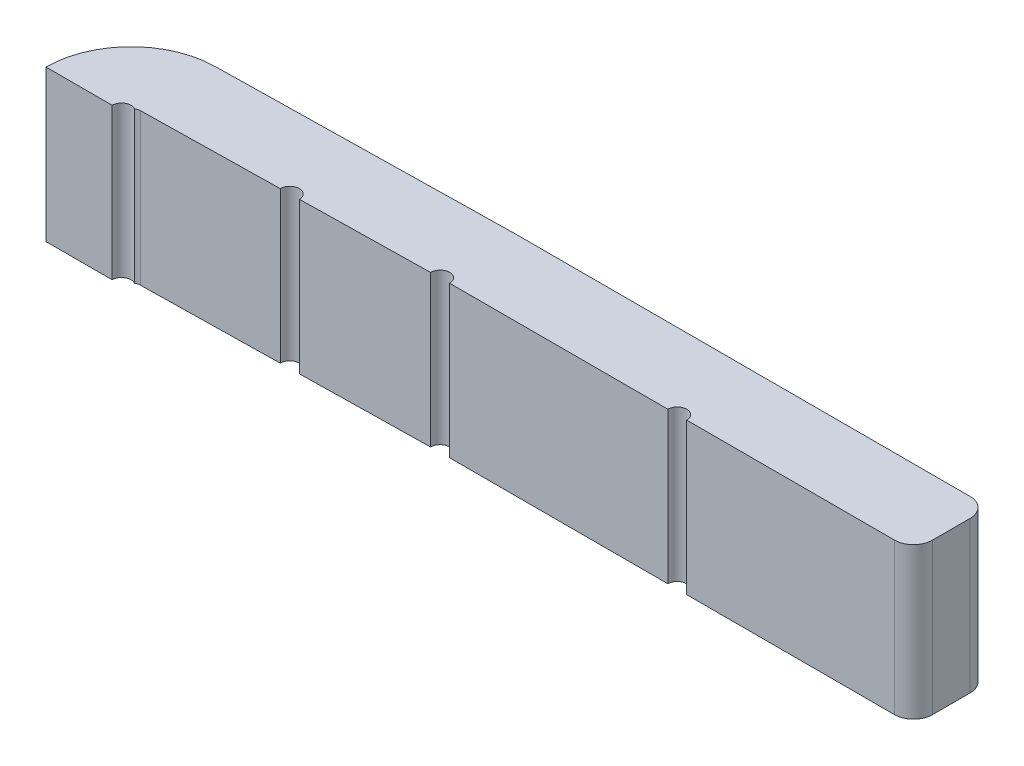
from build123d import *

# Parameters (mm, degrees)
BOSS_EXTRUDE1_DEPTH = 0.8
SKETCH2_R           = 0.05
CUT_EXTRUDE1_DEPTH  = 10
FILLET2_R           = 0.1


with BuildPart() as part:
    # Sketch1 → Boss-Extrude1 (new body)
    with BuildSketch(Plane(origin=(0, 0, 0), x_dir=(1, 0, 0), z_dir=(0, 1, 0))):
        with BuildLine():
            Line((-0.2, 0), (0.2, 0))
            ThreePointArc((0.2, 0), (0.214337478, 0.035045463), (0.24912738, 0.049992385))
            Line((0.24912738, 0.049992385), (1.804525368, 0.077141958))
            ThreePointArc((1.804525368, 0.077141958), (1.808888303, 0.077199072), (1.813251571, 0.07721811))
            Line((1.813251571, 0.07721811), (4.313251571, 0.07721811))
            Line((4.313251571, 0.07721811), (4.313251571, 0.47721811))
            Line((4.313251571, 0.47721811), (1.813251571, 0.47721811))
            ThreePointArc((1.813251571, 0.47721811), (1.805397689, 0.477183841), (1.797544405, 0.477081036))
            Line((1.797544405, 0.477081036), (0.242146417, 0.449931463))
            ThreePointArc((0.242146417, 0.449931463), (-0.070962702, 0.315409169), (-0.2, 0))
        make_face()
    boss_extrude1 = extrude(amount=BOSS_EXTRUDE1_DEPTH)

    # Mirror1: Boss-Extrude1 across Front Plane
    add(boss_extrude1.mirror(Plane.XY))

    # Sketch2 → Cut-Extrude1 (cut)
    with BuildSketch(Plane(origin=(0, 0.8, 0), x_dir=(1, 0, 0), z_dir=(0, 1, 0))):
        with Locations((0.2, 0)):
            Circle(SKETCH2_R)
        with Locations((1.808888303, 0.077199072)):
            Circle(SKETCH2_R)
        with Locations((3.063251571, 0.07721811)):
            Circle(SKETCH2_R)
        with Locations((1.026826374, 0.063567171)):
            Circle(SKETCH2_R)
    cut_extrude1 = extrude(amount=-CUT_EXTRUDE1_DEPTH, mode=Mode.SUBTRACT)

    # Mirror2: Cut-Extrude1 across plane
    add(cut_extrude1.mirror(Plane.XY), mode=Mode.SUBTRACT)

    # Fillet2
    fillet2_edges = [part.edges().sort_by_distance(p)[0] for p in [
        (4.313251571, 0.4, -0.47721811),
        (4.313251571, 0.4, -0.07721811),
        (4.313251571, 0.4, 0.47721811),
        (4.313251571, 0.4, 0.07721811),
    ]]
    fillet(fillet2_edges, radius=FILLET2_R)

    # SurfaceCut1
    split(bisect_by=Plane.XY, keep=Keep.BOTTOM)


solid = part.part
